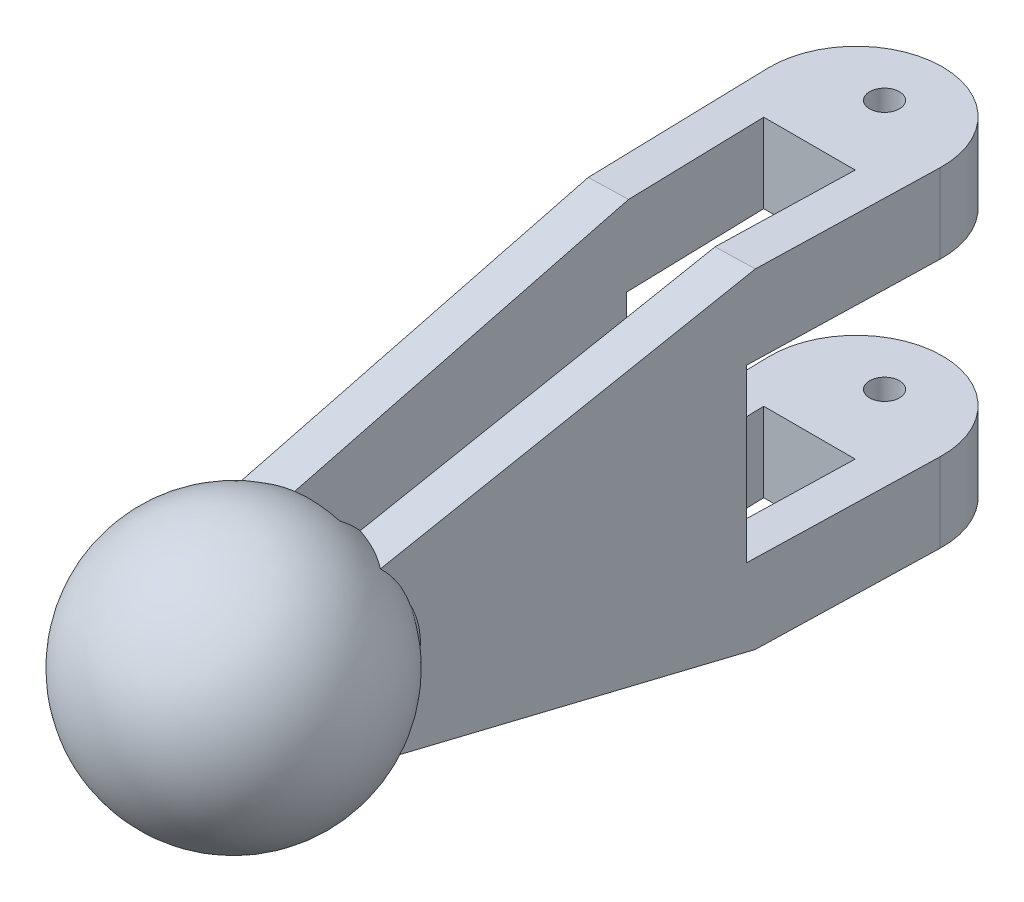
from build123d import *

# Parameters (mm, degrees)
BOSS_EXTRUDE1_DEPTH      = 53.34
SKETCH4_W                = 61.072672184
SKETCH4_H                = 27.686
CUT_EXTRUDE3_DEPTH       = 125.557157077
SKETCH5_OUTSIDE_W        = 57.352
SKETCH5_OUTSIDE_H        = 152.814
CUT_EXTRUDE5_DEPTH       = 123.51837945
SKETCH6_R                = 2.413
CUT_EXTRUDE6_DEPTH       = 123.51837945
CUT_EXTRUDE8_DEPTH       = 100
CUT_EXTRUDE8_DEPTH_BACK  = 100
CUT_EXTRUDE9_DEPTH       = 100
CUT_EXTRUDE10_DEPTH      = 128.352835601
CUT_EXTRUDE10_DEPTH_BACK = 128.352835601


with BuildPart() as part:
    # Sketch1 → Boss-Extrude1 (new body)
    with BuildSketch(Plane(origin=(0, 0, 0), x_dir=(1, 0, 0), z_dir=(0, 1, 0))):
        with BuildLine():
            Line((-13.944778991, -0.365156889), (-11.616850564, -89.265156889))
            ThreePointArc((-11.616850564, -89.265156889), (0, -109.412099434), (11.616850564, -89.265156889))
            Line((11.616850564, -89.265156889), (13.944778991, -0.365156889))
            ThreePointArc((13.944778991, -0.365156889), (0, 13.949559157), (-13.944778991, -0.365156889))
        make_face()
    extrude(amount=BOSS_EXTRUDE1_DEPTH)

    # Sketch4 → Cut-Extrude3 (cut, through all)
    with BuildSketch(Plane(origin=(13.944778991, 0, 0.365156889), x_dir=(0.026176948307873094, 0, -0.9996573249755574), z_dir=(0.9996573249755573, 0, 0.02617694830787309))):
        with Locations((0, 26.67)):
            Rectangle(SKETCH4_W, SKETCH4_H)
    extrude(amount=-CUT_EXTRUDE3_DEPTH, mode=Mode.SUBTRACT)

    # Sketch5 outside → Cut-Extrude5 (cut, through all)
    # profile 1 of 2: a face of its own
    with BuildSketch(Plane(origin=(0, 53.34, 0), x_dir=(1, 0, 0), z_dir=(0, 1, 0))):
        with Locations((0, -47.731)):
            Rectangle(SKETCH5_OUTSIDE_W, SKETCH5_OUTSIDE_H)
        with BuildLine():
            Line((-13.944778991, -0.365156889), (-11.616850564, -89.265156889))
            ThreePointArc((-11.616850564, -89.265156889), (0, -109.412099434), (11.616850564, -89.265156889))
            Line((11.616850564, -89.265156889), (13.944778991, -0.365156889))
            ThreePointArc((13.944778991, -0.365156889), (0, 13.949559157), (-13.944778991, -0.365156889))
        make_face(mode=Mode.SUBTRACT)
    # profile 2 of 2: a face of its own
    with BuildSketch(Plane(origin=(0, 53.34, 0), x_dir=(1, 0, 0), z_dir=(0, 1, 0))):
        with BuildLine():
            Line((7.403977553, -7.568443783), (5.213735587, -91.210409969))
            ThreePointArc((5.213735587, -91.210409969), (0, -105.33899845), (-5.213735587, -91.210409969))
            Line((-5.213735587, -91.210409969), (-7.403977553, -7.568443783))
            Line((-7.403977553, -7.568443783), (7.403977553, -7.568443783))
        make_face()
    extrude(amount=-CUT_EXTRUDE5_DEPTH, mode=Mode.SUBTRACT)

    # Sketch6 → Cut-Extrude6 (cut, through all)
    with BuildSketch(Plane(origin=(0, 53.34, 0), x_dir=(1, 0, 0), z_dir=(0, 1, 0))):
        with Locations((0, 4.57874024)):
            Circle(SKETCH6_R)
    extrude(amount=-CUT_EXTRUDE6_DEPTH, mode=Mode.SUBTRACT)

    # Sketch7 → Cut-Extrude8 (cut, two sides: drawn at the far end of the back side and taken through both)
    with BuildSketch(Plane(origin=(-13.944778991, 0, 0.365156889), x_dir=(0.02617694830787368, 0, 0.9996573249755574), z_dir=(-0.9996573249755574, 0, 0.02617694830787368)).offset(-CUT_EXTRUDE8_DEPTH_BACK)):
        Polygon((138.702727396, 53.34), (29.847177093, 53.34), (88.930474252, 40.09), (115.196693912, 40.09), (115.196693912, 13.25), (88.930474252, 13.25), (29.847177093, 0), (138.702727396, 0), align=None)
    extrude(amount=CUT_EXTRUDE8_DEPTH + CUT_EXTRUDE8_DEPTH_BACK, mode=Mode.SUBTRACT)

    # Sketch8 → Cut-Extrude9 (cut)
    with BuildSketch(Plane(origin=(0, 40.09, 0), x_dir=(1, 0, 0), z_dir=(0, 1, 0))):
        Polygon((-11.616850564, -89.265156889), (19.748470708, -88.443827046), (21.136276119, -119.73242467), (-27.769338844, -116.21935592), (-20.465853811, -89.265156889), align=None)
    extrude(amount=-CUT_EXTRUDE9_DEPTH, mode=Mode.SUBTRACT)


with BuildPart() as body_2:
    # Sketch14 → Revolve2 (revolve)
    with BuildSketch(Plane(origin=(0, 26.771336555, 0), x_dir=(-0.9996573249755574, 0, 0.02617694830787441), z_dir=(0, 1, 0))):
        with BuildLine():
            Line((7.599559157, 88.930474252), (2.320752522, 88.930474252))
            Line((2.320752522, 88.930474252), (2.320752522, 122.556421305))
            ThreePointArc((2.320752522, 122.556421305), (22.610323818, 108.131020534), (15.64993494, 84.228889302))
            Line((15.64993494, 84.228889302), (7.599559157, 74.699423181))
            Line((7.599559157, 74.699423181), (7.599559157, 88.930474252))
        make_face()
    revolve(axis=Axis((-1.162589714, 26.771336555, 44.258833564), (0.026176948307875366, 0, 0.9996573249755573)))

    # Sketch21 → Cut-Extrude10 (cut, two sides: drawn at the far end of the back side and taken through both)
    with BuildSketch(Plane(origin=(0, 26.771336555, 0), x_dir=(-0.9996573249755574, 0, 0.02617694830787441), z_dir=(0, 1, 0)).offset(-CUT_EXTRUDE10_DEPTH_BACK)):
        Polygon((7.599559157, 74.699423181), (-3.695157498, 74.699423181), (-2.949339715, 88.930474252), (7.599559157, 88.930474252), align=None)
    extrude(amount=CUT_EXTRUDE10_DEPTH + CUT_EXTRUDE10_DEPTH_BACK, mode=Mode.SUBTRACT)


solid = Compound([part.part, body_2.part])
